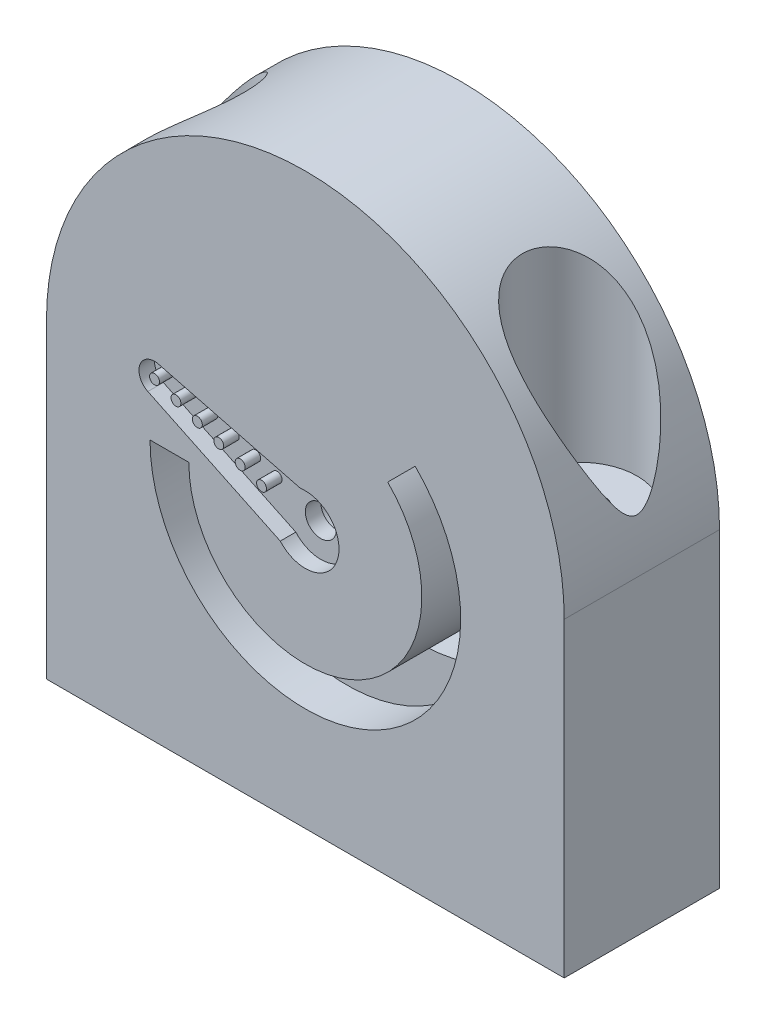
from build123d import *

# Parameters (mm, degrees)
BOSS_EXTRUDE1_DEPTH = 15
CUT_EXTRUDE1_REACH  = 17
CUT_EXTRUDE2_DEPTH  = 1.5
CUT_EXTRUDE3_REACH  = 15.5
SKETCH4_R           = 1.5
SKETCH5_R           = 2.5
CUT_EXTRUDE4_DEPTH  = 12
SKETCH6_R           = 0.48
BOSS_EXTRUDE2_DEPTH = 1.5
CUT_EXTRUDE5_REACH  = 57
SKETCH7_R           = 2.25
SKETCH8_R           = 5.54
CUT_EXTRUDE6_DEPTH  = 21
CUT_EXTRUDE7_REACH  = 57
SKETCH9_W           = 24
SKETCH9_H           = 7


with BuildPart() as part:
    # Sketch1 → Boss-Extrude1 (new body)
    with BuildSketch(Plane.XY):
        with BuildLine():
            Line((-25, 0), (-25, -30))
            Line((-25, -30), (25, -30))
            Line((25, -30), (25, 0))
            ThreePointArc((25, 0), (0, 25), (-25, 0))
        make_face()
    extrude(amount=BOSS_EXTRUDE1_DEPTH)

    # Sketch2 → Cut-Extrude1 (cut, up to next)
    with BuildSketch(Plane.XY.offset(15), mode=Mode.PRIVATE) as cut_extrude1_sk1:
        with BuildLine():
            Line((-15, -5), (-11.25, -5))
            ThreePointArc((-11.25, -5), (4.305188614, -15.393644741), (7.954951288, 2.954951288))
            Line((7.954951288, 2.954951288), (10.606601718, 5.606601718))
            ThreePointArc((10.606601718, 5.606601718), (5.740251485, -18.858192988), (-15, -5))
        make_face()
    cut_extrude1_tool1 = extrude(cut_extrude1_sk1.sketch, amount=-CUT_EXTRUDE1_REACH, mode=Mode.PRIVATE) & part.part
    add(cut_extrude1_tool1.solids().sort_by_distance((9.559676, 4.001877, 15))[0], mode=Mode.SUBTRACT)

    # Sketch3 → Cut-Extrude2 (cut)
    with BuildSketch(Plane.XY.offset(15)):
        with BuildLine():
            Line((-14.191020378, 1.753883373), (-0.462045472, -1.78301166))
            ThreePointArc((-0.462045472, -1.78301166), (3.054001018, -6.111565466), (-2.421787612, -7.167358937))
            Line((-2.421787612, -7.167358937), (-15.212264853, -1.05196276))
            ThreePointArc((-15.212264853, -1.05196276), (-15.974774553, 0.814342437), (-14.191020378, 1.753883373))
        make_face()
    extrude(amount=-CUT_EXTRUDE2_DEPTH, mode=Mode.SUBTRACT)

    # Sketch4 → Cut-Extrude3 (cut, up to next)
    with BuildSketch(Plane.XY.offset(13.5), mode=Mode.PRIVATE) as cut_extrude3_sk1:
        with Locations((0, -5)):
            Circle(SKETCH4_R)
    cut_extrude3_tool1 = extrude(cut_extrude3_sk1.sketch, amount=-CUT_EXTRUDE3_REACH, mode=Mode.PRIVATE) & part.part
    add(cut_extrude3_tool1.solids().sort_by_distance((0, -5, 13.5))[0], mode=Mode.SUBTRACT)

    # Sketch5 → Cut-Extrude4 (cut)
    with BuildSketch(Plane(origin=(0, 0, 0), x_dir=(-1, 0, 0), z_dir=(0, 0, -1))):
        with Locations((0, -5)):
            Circle(SKETCH5_R)
    extrude(amount=-CUT_EXTRUDE4_DEPTH, mode=Mode.SUBTRACT)

    # Sketch6 → Boss-Extrude2 (add)
    with BuildSketch(Plane.XY.offset(13.5)):
        with Locations((-14.565235622, 0.301312222)):
            Circle(SKETCH6_R)
        with Locations((-12.497911856, -0.451132094)):
            Circle(SKETCH6_R)
        with Locations((-10.430588091, -1.203576409)):
            Circle(SKETCH6_R)
        with Locations((-8.363264325, -1.956020724)):
            Circle(SKETCH6_R)
        with Locations((-6.295940559, -2.70846504)):
            Circle(SKETCH6_R)
        with Locations((-4.228616794, -3.460909355)):
            Circle(SKETCH6_R)
    extrude(amount=BOSS_EXTRUDE2_DEPTH)

    # Sketch7 → Cut-Extrude5 (cut, up to next)
    with BuildSketch(Plane.XZ.offset(30), mode=Mode.PRIVATE) as cut_extrude5_sk1:
        with Locations((-19, 7.5)):
            Circle(SKETCH7_R)
    cut_extrude5_tool1 = extrude(cut_extrude5_sk1.sketch, amount=-CUT_EXTRUDE5_REACH, mode=Mode.PRIVATE) & part.part
    add(cut_extrude5_tool1.solids().sort_by_distance((-19, -30, 7.5))[0], mode=Mode.SUBTRACT)
    # Sketch7 → Cut-Extrude5 (cut, up to next)
    with BuildSketch(Plane.XZ.offset(30), mode=Mode.PRIVATE) as cut_extrude5_sk2:
        with Locations((19, 7.5)):
            Circle(SKETCH7_R)
    cut_extrude5_tool2 = extrude(cut_extrude5_sk2.sketch, amount=-CUT_EXTRUDE5_REACH, mode=Mode.PRIVATE) & part.part
    add(cut_extrude5_tool2.solids().sort_by_distance((19, -30, 7.5))[0], mode=Mode.SUBTRACT)

    # Sketch8 → Cut-Extrude6 (cut)
    with BuildSketch(Plane(origin=(0, 23.467134405, 0), x_dir=(1, 0, 0), z_dir=(0, 1, 0))):
        with Locations((-19, -7.5)):
            Circle(SKETCH8_R)
        with Locations((19, -7.5)):
            Circle(SKETCH8_R)
    extrude(amount=-CUT_EXTRUDE6_DEPTH, mode=Mode.SUBTRACT)

    # Sketch9 → Cut-Extrude7 (cut, up to next)
    with BuildSketch(Plane.XZ.offset(30), mode=Mode.PRIVATE) as cut_extrude7_sk1:
        with Locations((0, 7.5)):
            Rectangle(SKETCH9_W, SKETCH9_H)
    cut_extrude7_tool1 = extrude(cut_extrude7_sk1.sketch, amount=-CUT_EXTRUDE7_REACH, mode=Mode.PRIVATE) & part.part
    add(cut_extrude7_tool1.solids().sort_by_distance((0, -30, 7.5))[0], mode=Mode.SUBTRACT)


solid = part.part
